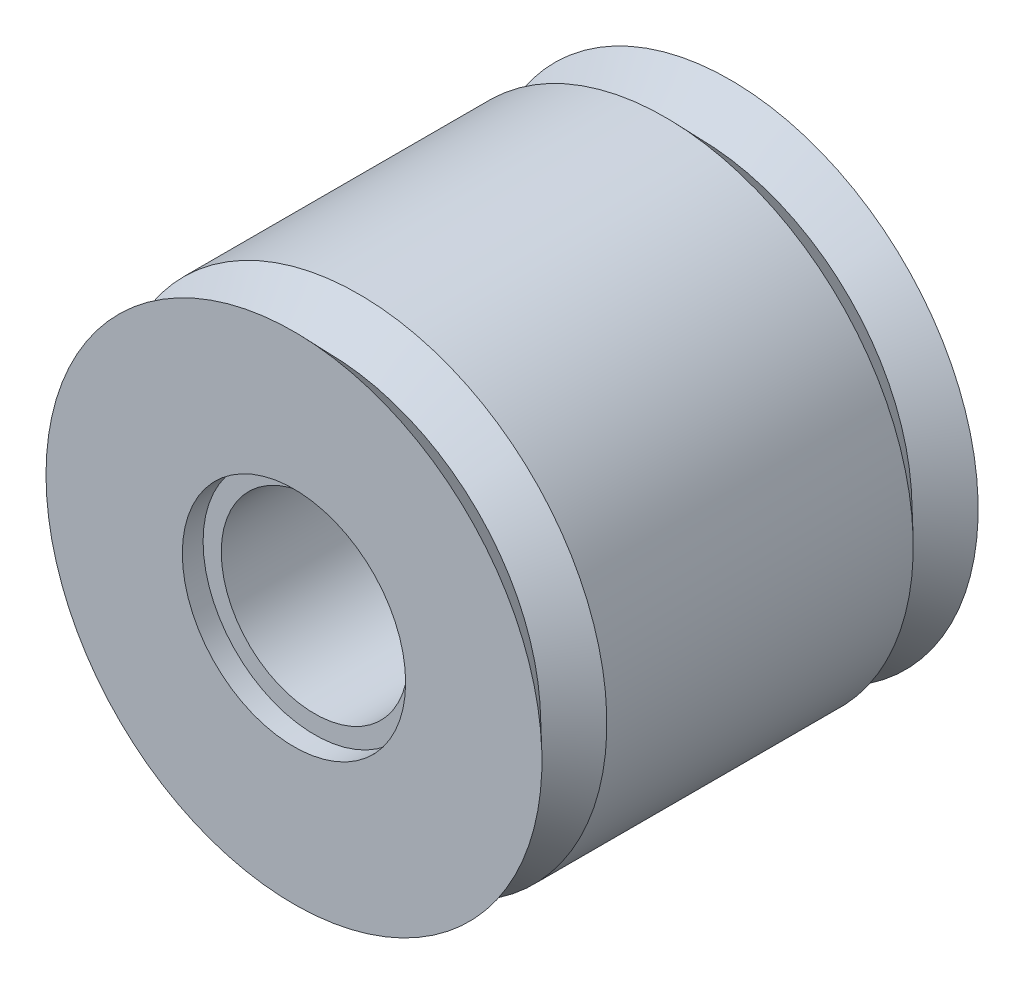
from build123d import *

# Parameters (mm, degrees)
SKETCH_1_R          = 9.55
SKETCH_1_R_2        = 3.6
EXTRUDE_1_DEPTH     = 8.4
SKETCH_2_R          = 4.3
CUT_EXTRUDE_1_DEPTH = 0.8


with BuildPart() as part:
    # 스케치1 → 보스-돌출1 (new body, symmetric)
    with BuildSketch(Plane.XY):
        Circle(SKETCH_1_R)
        Circle(SKETCH_1_R_2, mode=Mode.SUBTRACT)
    extrude(amount=EXTRUDE_1_DEPTH, both=True)

    # 스케치2 → 컷-돌출1 (cut)
    with BuildSketch(Plane.XY.offset(8.4)):
        Circle(SKETCH_2_R)
    cut_extrude_1 = extrude(amount=-CUT_EXTRUDE_1_DEPTH, mode=Mode.SUBTRACT)

    # 스케치3 → 컷-회전1 (revolve, cut)
    with BuildSketch(Plane(origin=(0, 0, 0), x_dir=(0, 0, -1), z_dir=(1, 0, 0))):
        Polygon((-8.4, 9.55), (-5.9, 9.55), (-7.15, 8.25), align=None)
    cut_revolve_1 = revolve(axis=Axis((0, 0, 0), (0, 0, 1)), mode=Mode.SUBTRACT)

    # 대칭 복사1: 컷-돌출1, 컷-회전1 across plane
    add(cut_extrude_1.mirror(Plane.XY), mode=Mode.SUBTRACT)
    add(cut_revolve_1.mirror(Plane.XY), mode=Mode.SUBTRACT)


solid = part.part
